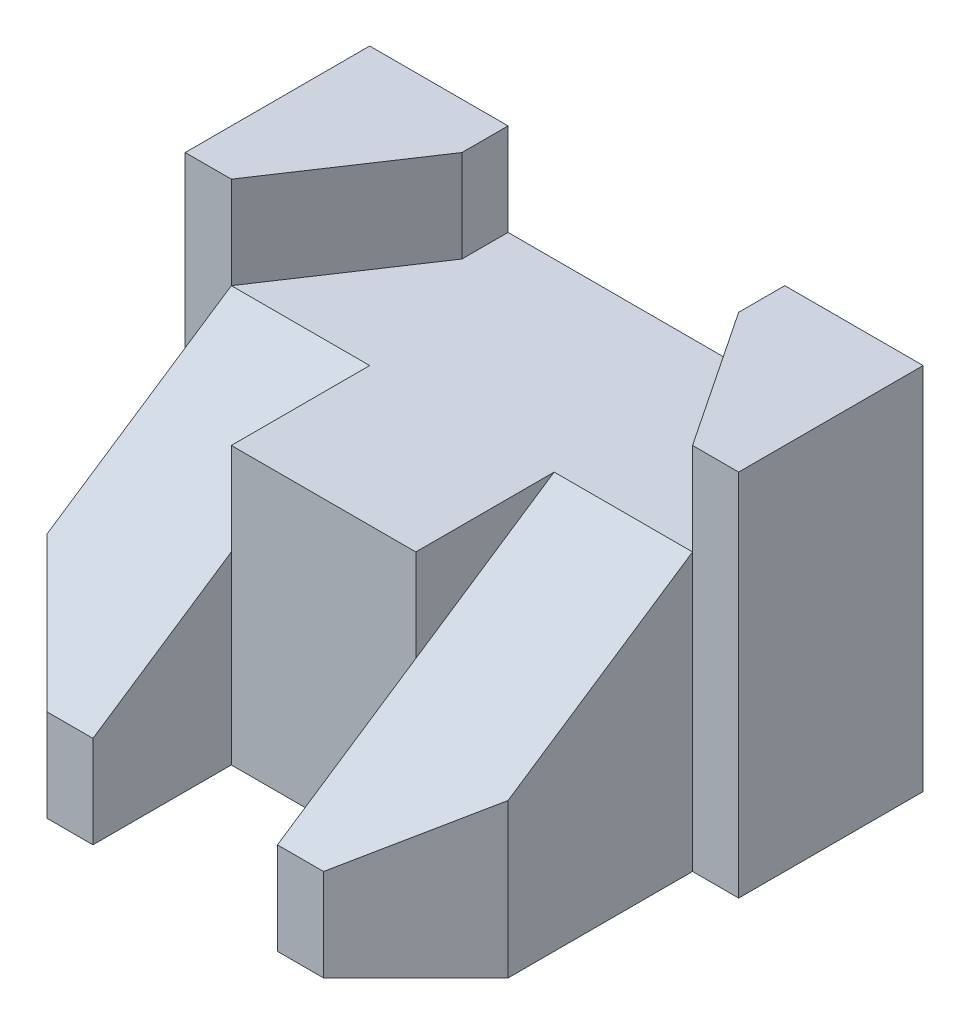
from build123d import *

# Parameters (mm, degrees)
SKETCH1_W           = 120
SKETCH1_H           = 100
BOSS_EXTRUDE1_DEPTH = 80
SKETCH2_W           = 40
SKETCH2_H           = 30
CUT_EXTRUDE1_DEPTH  = 80
CUT_EXTRUDE2_DEPTH  = 80
CUT_EXTRUDE6_DEPTH  = 20
SKETCH5_W           = 29.999
SKETCH5_H           = 20
CUT_EXTRUDE7_DEPTH  = 68
SKETCH6_W           = 40.001
SKETCH6_H           = 20
CUT_EXTRUDE8_DEPTH  = 68
SKETCH7_W           = 40.001
SKETCH7_H           = 20
CUT_EXTRUDE9_DEPTH  = 68
CUT_EXTRUDE10_DEPTH = 68
SKETCH13_W          = 29.999
SKETCH13_H          = 72.111025509
CUT_EXTRUDE11_DEPTH = 68
CUT_EXTRUDE12_DEPTH = 68


with BuildPart() as part:
    # Sketch1 → Boss-Extrude1 (new body)
    with BuildSketch(Plane(origin=(0, 0, 0), x_dir=(1, 0, 0), z_dir=(0, 1, 0))):
        with Locations((60, 50)):
            Rectangle(SKETCH1_W, SKETCH1_H)
    extrude(amount=BOSS_EXTRUDE1_DEPTH)

    # Sketch2 → Cut-Extrude1 (cut)
    with BuildSketch(Plane(origin=(0, 80, 0), x_dir=(1, 0, 0), z_dir=(0, 1, 0))):
        with Locations((60, 15)):
            Rectangle(SKETCH2_W, SKETCH2_H)
    extrude(amount=-CUT_EXTRUDE1_DEPTH, mode=Mode.SUBTRACT)

    # Sketch3 → Cut-Extrude2 (cut)
    with BuildSketch(Plane(origin=(0, 80, 0), x_dir=(1, 0, 0), z_dir=(0, 1, 0))):
        Polygon((0, 60), (10, 60), (10, 20), (30, 0), (0, 0), align=None)
        Polygon((120, 60), (110, 60), (110, 20), (90, 0), (120, 0), align=None)
    extrude(amount=-CUT_EXTRUDE2_DEPTH, mode=Mode.SUBTRACT)

    # Sketch4 → Cut-Extrude6 (cut)
    with BuildSketch(Plane(origin=(0, 80, 0), x_dir=(1, 0, 0), z_dir=(0, 1, 0))):
        Polygon((30, 100), (90, 100), (90, 90), (109.999, 60), (80, 60), (80, 30), (40, 30), (40, 60), (10.001, 60), (30, 90), align=None)
    extrude(amount=-CUT_EXTRUDE6_DEPTH, mode=Mode.SUBTRACT)

    # Sketch5 → Cut-Extrude7 (cut)
    with BuildSketch(Plane(origin=(0, 0, -60), x_dir=(-1, 0, 0), z_dir=(0, 0, -1))):
        with Locations((-94.9995, 70)):
            Rectangle(SKETCH5_W, SKETCH5_H)
        with Locations((-25.0005, 70)):
            Rectangle(SKETCH5_W, SKETCH5_H)
    extrude(amount=-CUT_EXTRUDE7_DEPTH, mode=Mode.SUBTRACT)

    # Sketch6 → Cut-Extrude8 (cut)
    with BuildSketch(Plane.ZY.offset(-109.999)):
        with Locations((-39.9995, 70)):
            Rectangle(SKETCH6_W, SKETCH6_H)
    extrude(amount=-CUT_EXTRUDE8_DEPTH, mode=Mode.SUBTRACT)

    # Sketch7 → Cut-Extrude9 (cut)
    with BuildSketch(Plane(origin=(10.001, 0, 0), x_dir=(0, 0, -1), z_dir=(1, 0, 0))):
        with Locations((39.9995, 70)):
            Rectangle(SKETCH7_W, SKETCH7_H)
    extrude(amount=-CUT_EXTRUDE9_DEPTH, mode=Mode.SUBTRACT)

    # Sketch10 → Cut-Extrude10 (cut)
    with BuildSketch(Plane(origin=(-5e-09, 13.846153834, 9.230769225), x_dir=(1, 0, 0), z_dir=(0, 0.832050294, 0.554700196))):
        Polygon((40.001000005, 83.205029422), (40.000000005, 11.094003927), (10.000000005, 11.094003927), (10.000000005, 83.205029436), align=None)
    extrude(amount=CUT_EXTRUDE10_DEPTH, mode=Mode.SUBTRACT)

    # Sketch13 → Cut-Extrude11 (cut)
    with BuildSketch(Plane(origin=(0, 13.846153846, 9.230769231), x_dir=(-1, 0, 0), z_dir=(0, -0.832050294, -0.554700196))):
        with Locations((-94.9995, 47.14951668)):
            Rectangle(SKETCH13_W, SKETCH13_H)
    extrude(amount=-CUT_EXTRUDE11_DEPTH, mode=Mode.SUBTRACT)

    # Sketch14 → Cut-Extrude12 (cut)
    with BuildSketch(Plane.ZY.offset(-109.999)):
        Polygon((-60, 60), (-19.999, 33.332666667), (-19.999, 60), align=None)
    extrude(amount=-CUT_EXTRUDE12_DEPTH, mode=Mode.SUBTRACT)


solid = part.part
